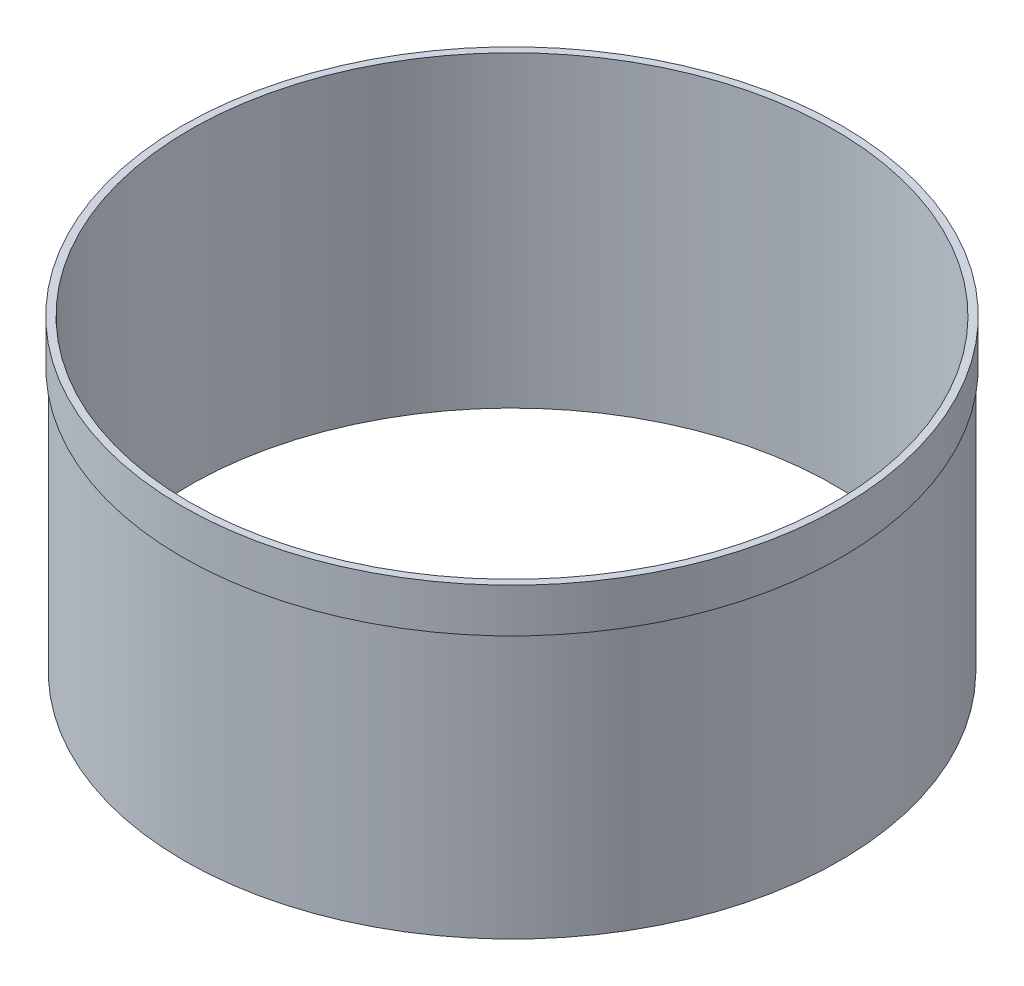
from build123d import *

# Parameters (mm, degrees)
SKETCH1_R           = 94.742
SKETCH1_R_2         = 93.1545
BOSS_EXTRUDE1_DEPTH = 88.9
SKETCH2_R           = 95.25
SKETCH2_R_2         = 94.742
BOSS_EXTRUDE2_DEPTH = 12.7


with BuildPart() as part:
    # Sketch1 → Boss-Extrude1 (new body)
    with BuildSketch(Plane(origin=(0, 0, 0), x_dir=(1, 0, 0), z_dir=(0, 1, 0))):
        Circle(SKETCH1_R)
        Circle(SKETCH1_R_2, mode=Mode.SUBTRACT)
    extrude(amount=BOSS_EXTRUDE1_DEPTH)

    # Sketch2 → Boss-Extrude2 (add)
    with BuildSketch(Plane(origin=(0, 88.9, 0), x_dir=(1, 0, 0), z_dir=(0, 1, 0))):
        Circle(SKETCH2_R)
        Circle(SKETCH2_R_2, mode=Mode.SUBTRACT)
    extrude(amount=-BOSS_EXTRUDE2_DEPTH)


solid = part.part
